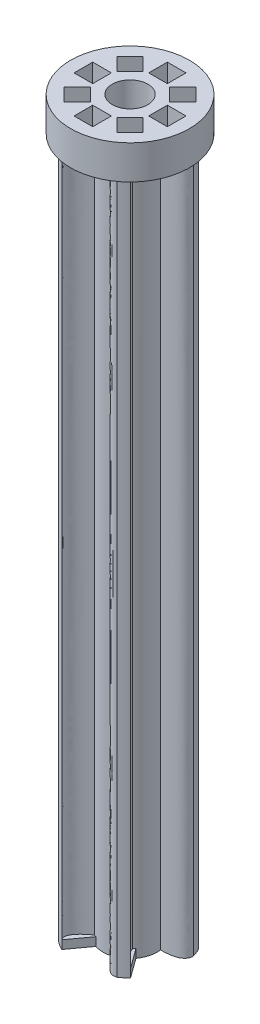
from build123d import *

# Parameters (mm, degrees)
SKETCH1_R           = 1.6
SKETCH1_R_2         = 1.1
BOSS_EXTRUDE1_DEPTH = 41
SKETCH2_R           = 3
SKETCH2_R_2         = 1.05
BOSS_EXTRUDE2_DEPTH = 2
SKETCH4_W           = 1.1
SKETCH4_H           = 1.1
CUT_EXTRUDE2_DEPTH  = 1.5
CIRPATTERN2_COUNT   = 8
BOSS_EXTRUDE3_DEPTH = 41
BOSS_EXTRUDE4_DEPTH = 0.5
CIRPATTERN3_COUNT   = 5
SKETCH9_R           = 3.5
SKETCH9_R_2         = 3
BOSS_EXTRUDE5_DEPTH = 2


with BuildPart() as part:
    # Sketch1 → Boss-Extrude1 (new body)
    with BuildSketch(Plane(origin=(0, 0, 0), x_dir=(1, 0, 0), z_dir=(0, 1, 0))):
        Circle(SKETCH1_R)
        Circle(SKETCH1_R_2, mode=Mode.SUBTRACT)
    extrude(amount=BOSS_EXTRUDE1_DEPTH)

    # Sketch2 → Boss-Extrude2 (add)
    with BuildSketch(Plane(origin=(0, 41, 0), x_dir=(1, 0, 0), z_dir=(0, 1, 0))):
        Circle(SKETCH2_R)
        Circle(SKETCH2_R_2, mode=Mode.SUBTRACT)
    extrude(amount=BOSS_EXTRUDE2_DEPTH)

    # Sketch4 → Cut-Extrude2 (cut)
    with BuildSketch(Plane(origin=(0, 43, 0), x_dir=(1, 0, 0), z_dir=(0, 1, 0))):
        with Locations((0, 2.2)):
            Rectangle(SKETCH4_W, SKETCH4_H)
    cut_extrude2 = extrude(amount=-CUT_EXTRUDE2_DEPTH, mode=Mode.SUBTRACT)

    # CirPattern2: Cut-Extrude2 ×8 about axis
    cirpattern2_axis = Axis((0, 0, 0), (0, 1, 0))
    for i in range(1, CIRPATTERN2_COUNT):
        add(cut_extrude2.rotate(cirpattern2_axis, i * 360 / CIRPATTERN2_COUNT), mode=Mode.SUBTRACT)

    # Sketch6 → Boss-Extrude3 (add)
    with BuildSketch(Plane.XZ.offset(-41)):
        with BuildLine():
            ThreePointArc((1.58647512, -0.20759743), (1.511644009, -0.524339955), (1.374265367, -0.819386783))
            add(Edge.make_bspline(
                [(1.374265367, -0.819386783), (2.663604789, -0.829341718), (2.663604789, -1.380293276)],
                knots=[0, 0, 0, 1, 1, 1], degree=2))
            ThreePointArc((2.663604789, -1.380293276), (2.781312042, -1.124412436), (2.874503573, -0.858620525))
            add(Edge.make_bspline(
                [(1.58647512, -0.20759743), (2.874503573, -0.20759743), (2.874503573, -0.858620525)],
                knots=[0, 0, 0, 1, 1, 1], degree=2))
        make_face()
    boss_extrude3 = extrude(amount=BOSS_EXTRUDE3_DEPTH)

    # Sketch7 → Boss-Extrude4 (add)
    with BuildSketch(Plane(origin=(0, 0, 0), x_dir=(1, 0, 0), z_dir=(0, 1, 0))):
        with BuildLine():
            Line((1.297621609, 0.936043888), (2.663604789, 1.380293276))
            add(Edge.make_bspline(
                [(1.374265367, 0.819386783), (2.874503573, 0.858620525), (2.663604789, 1.380293276)],
                knots=[0, 0, 0, 1, 1, 1], degree=2))
            ThreePointArc((1.374265367, 0.819386783), (1.337216222, 0.878551522), (1.297621609, 0.936043888))
        make_face()
    boss_extrude4 = extrude(amount=BOSS_EXTRUDE4_DEPTH)

    # CirPattern3: Boss-Extrude3, Boss-Extrude4 ×5 about axis
    cirpattern3_axis = Axis((0, 41, 0), (0, -1, 0))
    for i in range(1, CIRPATTERN3_COUNT):
        add(boss_extrude3.rotate(cirpattern3_axis, i * 360 / CIRPATTERN3_COUNT))
        add(boss_extrude4.rotate(cirpattern3_axis, i * 360 / CIRPATTERN3_COUNT))

    # Sketch9 → Boss-Extrude5 (add)
    with BuildSketch(Plane.XZ.offset(-41)):
        Circle(SKETCH9_R)
        Circle(SKETCH9_R_2, mode=Mode.SUBTRACT)
    extrude(amount=-BOSS_EXTRUDE5_DEPTH)


solid = part.part
